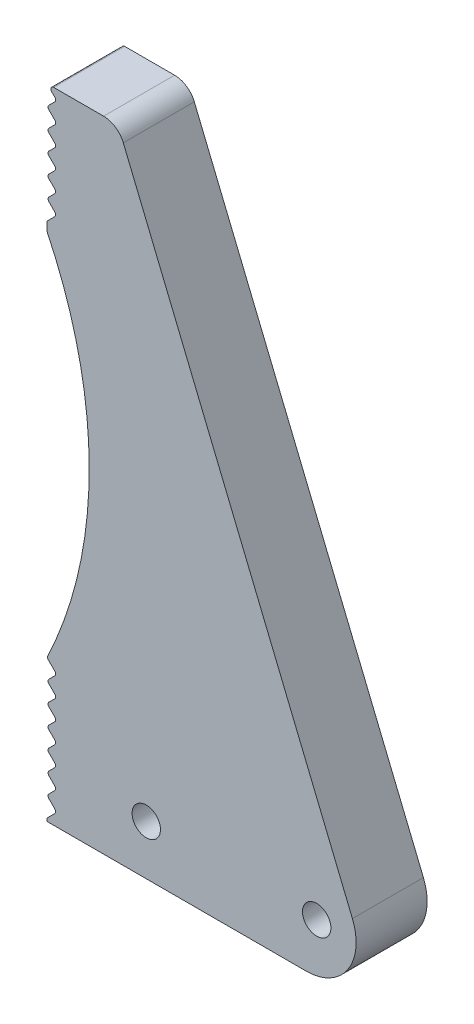
from build123d import *

# Parameters (mm, degrees)
SKETCH1_R      = 1
EXTRUDE2_DEPTH = 5
FILLET2_R      = 3.5
FILLET3_R      = 1.5
EXTRUDE4_DEPTH = 5
FILLET4_R      = 0.2
EXTRUDE5_DEPTH = 5
FILLET5_R      = 0.2


with BuildPart() as part:
    # Sketch1 → Extrude2 (new body)
    with BuildSketch(Plane.XY):
        with BuildLine():
            Line((-30.522603834, 36.180351438), (-30.522603834, 45.180351438))
            Line((-30.522603834, 45.180351438), (-25.522603834, 45.180351438))
            Line((-25.522603834, 45.180351438), (-7.022603834, 0.180351438))
            Line((-7.022603834, 0.180351438), (-30.522603834, 0.180351438))
            Line((-30.522603834, 0.180351438), (-30.522603834, 10.180351438))
            ThreePointArc((-30.522603834, 10.180351438), (-27.540232283, 23.180351438), (-30.522603834, 36.180351438))
        make_face()
        with Locations((-23.522603834, 3.680351438)):
            Circle(SKETCH1_R, mode=Mode.SUBTRACT)
        with Locations((-11.522603834, 3.680351438)):
            Circle(SKETCH1_R, mode=Mode.SUBTRACT)
    extrude(amount=EXTRUDE2_DEPTH)

    # Fillet2
    fillet2_edges = [part.edges().sort_by_distance(p)[0] for p in [
        (-7.022603834, 0.180351438, 2.5),
    ]]
    fillet(fillet2_edges, radius=FILLET2_R)

    # Fillet3
    fillet3_edges = [part.edges().sort_by_distance(p)[0] for p in [
        (-25.522603834, 45.180351438, 2.5),
    ]]
    fillet(fillet3_edges, radius=FILLET3_R)

    # Sketch3 → Extrude4 (cut)
    with BuildSketch(Plane.XY.offset(5)):
        Polygon((-29.822603834, 43.080351438), (-30.522603834, 43.780351438), (-30.522603834, 42.380351438), align=None)
        Polygon((-29.822603834, 44.480351438), (-30.522603834, 45.180351438), (-30.522603834, 43.780351438), align=None)
        Polygon((-29.822603834, 41.680351438), (-30.522603834, 42.380351438), (-30.522603834, 40.980351438), align=None)
        Polygon((-29.822603834, 40.280351438), (-30.522603834, 40.980351438), (-30.522603834, 39.580351438), align=None)
        Polygon((-29.822603834, 38.880351438), (-30.522603834, 39.580351438), (-30.522603834, 38.180351438), align=None)
        Polygon((-29.822603834, 37.480351438), (-30.522603834, 38.180351438), (-30.522603834, 36.780351438), align=None)
    extrude(amount=-EXTRUDE4_DEPTH, mode=Mode.SUBTRACT)

    # Fillet4
    fillet4_edges = [part.edges().sort_by_distance(p)[0] for p in [
        (-30.522603834, 45.180351438, 2.5),
        (-29.822603834, 43.080351438, 2.5),
        (-30.522603834, 42.380351438, 2.5),
        (-30.522603834, 43.780351438, 2.5),
        (-29.822603834, 44.480351438, 2.5),
        (-29.822603834, 41.680351438, 2.5),
        (-30.522603834, 40.980351438, 2.5),
        (-29.822603834, 40.280351438, 2.5),
        (-30.522603834, 39.580351438, 2.5),
        (-29.822603834, 38.880351438, 2.5),
        (-30.522603834, 38.180351438, 2.5),
        (-29.822603834, 37.480351438, 2.5),
        (-30.522603834, 36.780351438, 2.5),
    ]]
    fillet(fillet4_edges, radius=FILLET4_R)

    # Sketch4 → Extrude5 (cut)
    with BuildSketch(Plane.XY.offset(5)):
        Polygon((-29.822603834, 1.080351438), (-30.522603834, 1.780351438), (-30.522603834, 0.380351438), align=None)
        Polygon((-29.822603834, 2.480351438), (-30.522603834, 3.180351438), (-30.522603834, 1.780351438), align=None)
        Polygon((-29.822603834, 3.880351438), (-30.522603834, 4.580351438), (-30.522603834, 3.180351438), align=None)
        Polygon((-29.822603834, 5.280351438), (-30.522603834, 5.980351438), (-30.522603834, 4.580351438), align=None)
        Polygon((-29.822603834, 6.680351438), (-30.522603834, 7.380351438), (-30.522603834, 5.980351438), align=None)
        Polygon((-29.822603834, 8.080351438), (-30.522603834, 8.780351438), (-30.522603834, 7.380351438), align=None)
        Polygon((-29.822603834, 9.480351438), (-30.522603834, 10.180351438), (-30.522603834, 8.780351438), align=None)
    extrude(amount=-EXTRUDE5_DEPTH, mode=Mode.SUBTRACT)

    # Fillet5
    fillet5_edges = [part.edges().sort_by_distance(p)[0] for p in [
        (-30.522603834, 10.180351438, 2.5),
        (-29.822603834, 2.480351438, 2.5),
        (-30.522603834, 1.780351438, 2.5),
        (-29.822603834, 3.880351438, 2.5),
        (-30.522603834, 3.180351438, 2.5),
        (-29.822603834, 5.280351438, 2.5),
        (-30.522603834, 4.580351438, 2.5),
        (-29.822603834, 6.680351438, 2.5),
        (-30.522603834, 5.980351438, 2.5),
        (-29.822603834, 8.080351438, 2.5),
        (-30.522603834, 7.380351438, 2.5),
        (-29.822603834, 9.480351438, 2.5),
        (-30.522603834, 8.780351438, 2.5),
        (-29.822603834, 1.080351438, 2.5),
        (-30.522603834, 0.380351438, 2.5),
    ]]
    fillet(fillet5_edges, radius=FILLET5_R)


solid = part.part
